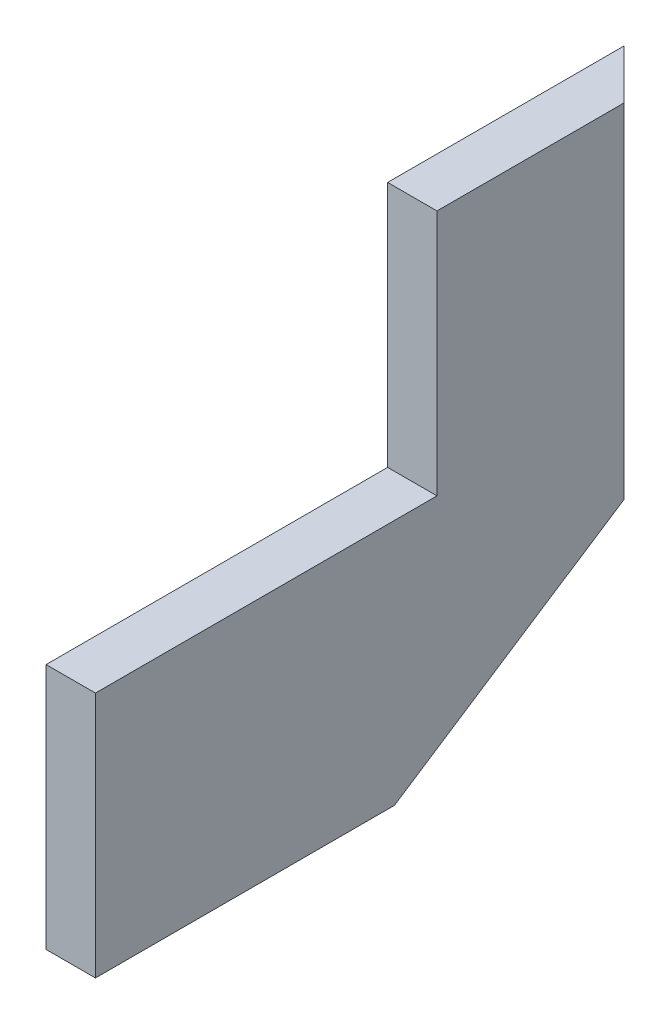
from build123d import *

# Parameters (mm, degrees)
BOSS_EXTRUDE2_DEPTH = 38.1
CUT_EXTRUDE1_REACH  = 383


with BuildPart() as part:
    # Sketch1 → Boss-Extrude2 (new body)
    with BuildSketch(Plane(origin=(0, 0, 0), x_dir=(0, 0, -1), z_dir=(1, 0, 0))):
        Polygon((230.790126839, 0), (446.057536726, 140.777827649), (446.057536726, 381), (263.652, 381), (263.652, 190.5), (0, 190.5), (0, 0), align=None)
    extrude(amount=BOSS_EXTRUDE2_DEPTH)

    # Sketch2 → Cut-Extrude1 (cut, up to next)
    with BuildSketch(Plane(origin=(0, 381, 0), x_dir=(1, 0, 0), z_dir=(0, 1, 0)), mode=Mode.PRIVATE) as cut_extrude1_sk1:
        Polygon((0, 446.057536726), (38.1, 407.957536726), (38.1, 446.057536726), align=None)
    cut_extrude1_tool1 = extrude(cut_extrude1_sk1.sketch, amount=-CUT_EXTRUDE1_REACH, mode=Mode.PRIVATE) & part.part
    add(cut_extrude1_tool1.solids().sort_by_distance((25.4, 381, -433.357537))[0], mode=Mode.SUBTRACT)


solid = part.part
